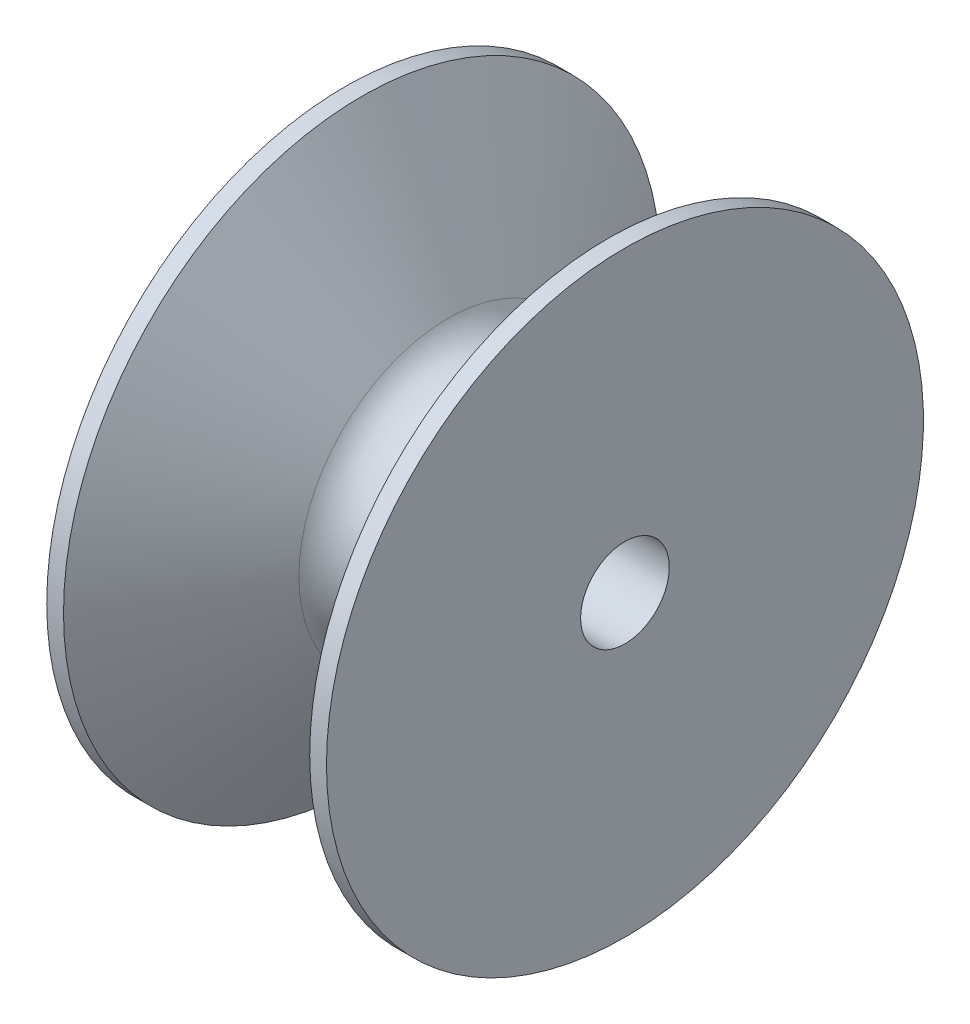
from build123d import *


with BuildPart() as part:
    # Sketch1 → Revolve1 (revolve)
    with BuildSketch(Plane.XY):
        with BuildLine():
            Line((0, 1.651), (10.414, 1.651))
            Line((10.414, 1.651), (10.414, 11.1125))
            Line((10.414, 11.1125), (9.789717762, 11.1125))
            Line((9.789717762, 11.1125), (6.581815329, 5.55625))
            ThreePointArc((6.581815329, 5.55625), (5.207, 4.7625), (3.832184671, 5.55625))
            Line((3.832184671, 5.55625), (0.624282238, 11.1125))
            Line((0.624282238, 11.1125), (0, 11.1125))
            Line((0, 11.1125), (0, 1.651))
        make_face()
    revolve(axis=Axis((0, 0, 0), (1, 0, 0)))


solid = part.part
